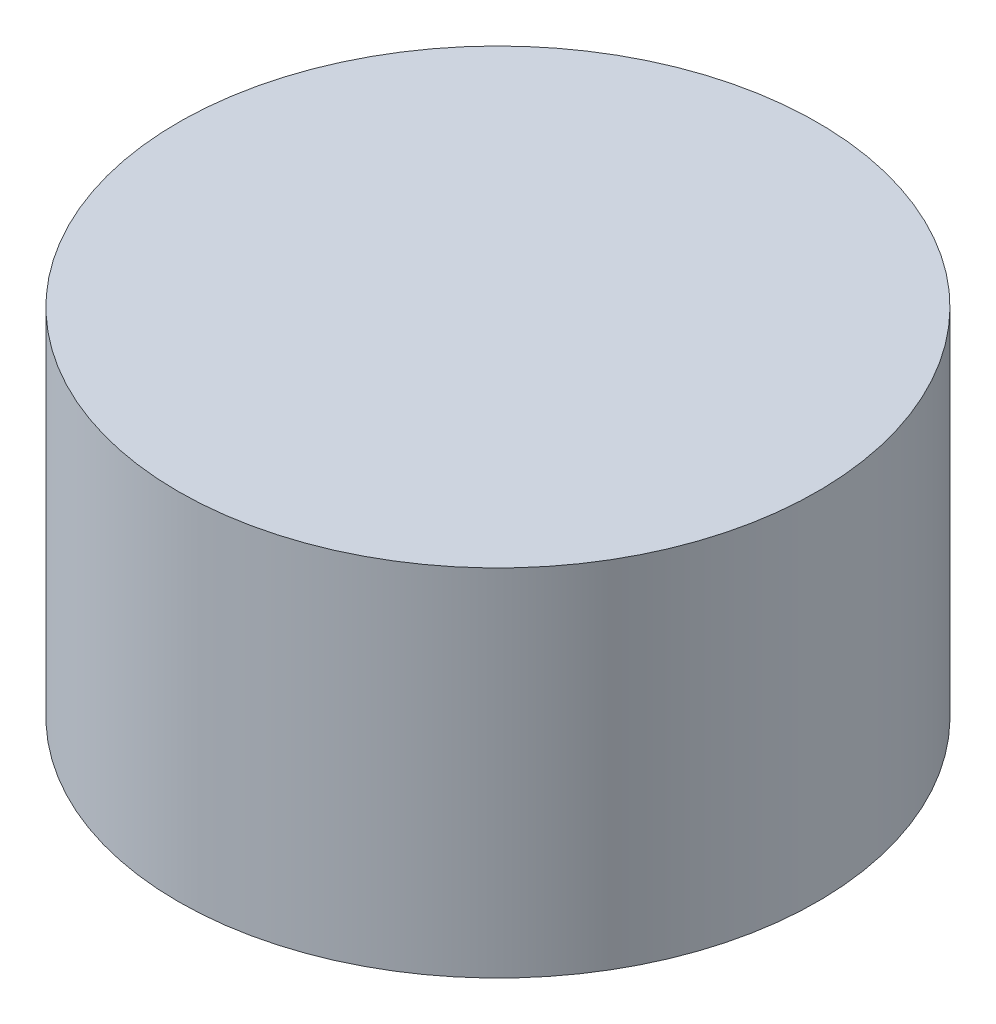
from build123d import *

# Parameters (mm, degrees)
SKETCH1_R           = 13.5
BOSS_EXTRUDE1_DEPTH = 15


with BuildPart() as part:
    # Sketch1 → Boss-Extrude1 (new body)
    with BuildSketch(Plane(origin=(0, 0, 0), x_dir=(1, 0, 0), z_dir=(0, 1, 0))):
        Circle(SKETCH1_R)
    extrude(amount=BOSS_EXTRUDE1_DEPTH)


solid = part.part
